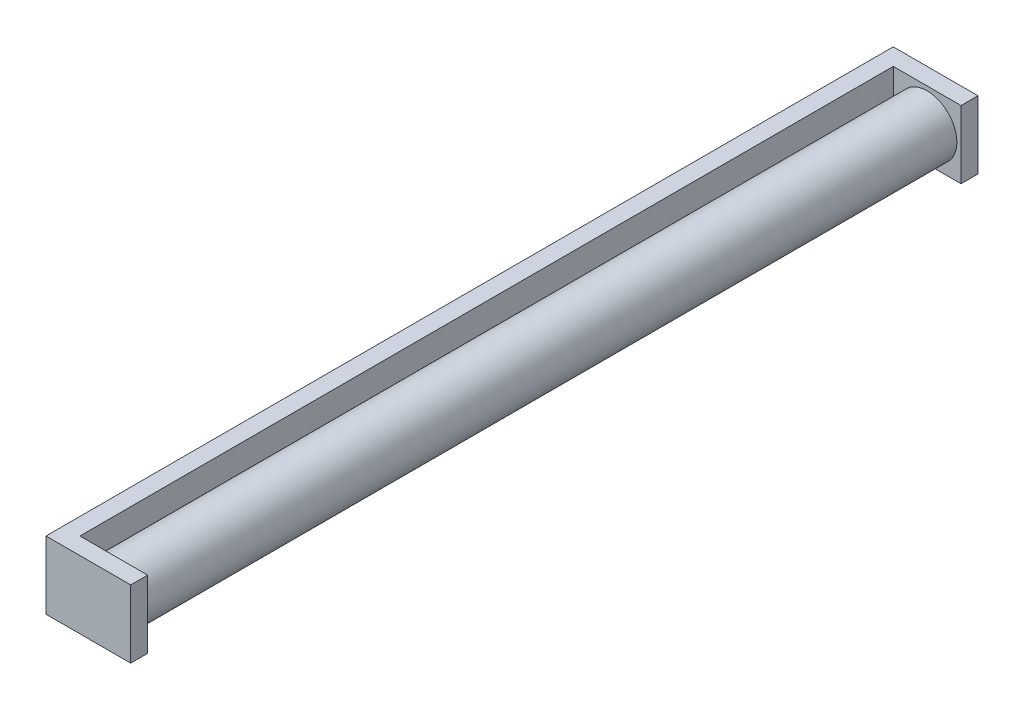
from build123d import *

# Parameters (mm, degrees)
SKETCH_1_W        = 1000
SKETCH_1_H        = 80
EXTRUDE_1_DEPTH   = 20
SKETCH_2_W        = 20
SKETCH_2_H        = 80
EXTRUDE_1_2_DEPTH = 80
SKETCH_3_R        = 35
EXTRUDE_2_DEPTH   = 980


with BuildPart() as part:
    # 草图1 → Extrude 1 (new body)
    with BuildSketch(Plane(origin=(0, 0, 0), x_dir=(0, 0, -1), z_dir=(1, 0, 0))):
        Rectangle(SKETCH_1_W, SKETCH_1_H)
    extrude(amount=EXTRUDE_1_DEPTH)

    # 草图2 → Extrude 1 2 (add)
    with BuildSketch(Plane(origin=(20, 0, 0), x_dir=(0, 0, -1), z_dir=(1, 0, 0))):
        with Locations((-490, 0)):
            Rectangle(SKETCH_2_W, SKETCH_2_H)
    extrude_1_2 = extrude(amount=EXTRUDE_1_2_DEPTH)

    # 镜向1: Extrude 1 2 across plane
    add(extrude_1_2.mirror(Plane.XY))

    # 草图3 → 凸台-拉伸2 (add)
    with BuildSketch(Plane.XY.offset(500)):
        with Locations((60, 0)):
            Circle(SKETCH_3_R)
    extrude(amount=-EXTRUDE_2_DEPTH)


solid = part.part
